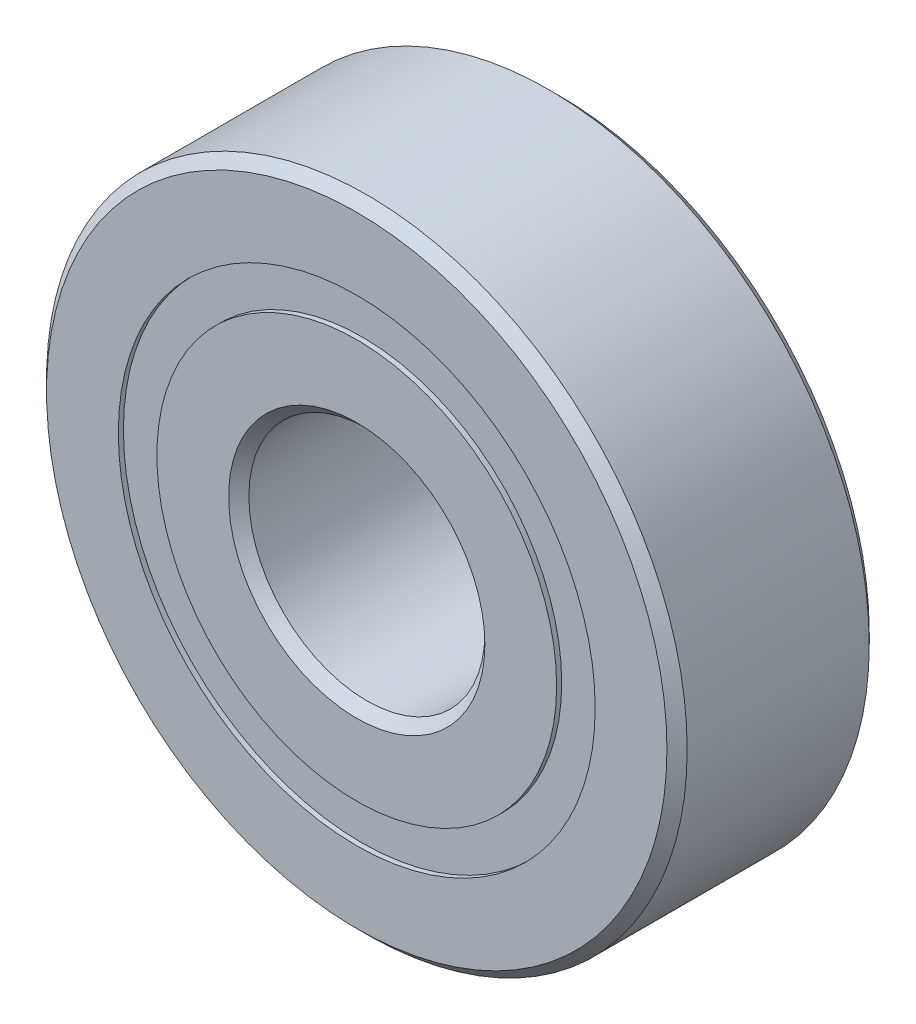
from build123d import *

# Parameters (mm, degrees)
CIRPATTERN1_COUNT = 12
SKETCH5_W         = 1.399376551
SKETCH5_H         = 1.142857142


with BuildPart() as part:
    # Sketch1 → Revolve1 (revolve)
    with BuildSketch(Plane(origin=(0, 0, 0), x_dir=(0, 0, -1), z_dir=(1, 0, 0))):
        with BuildLine():
            Line((2.7, 9.5), (-2.7, 9.5))
            Line((-2.7, 9.5), (-3, 9.2))
            Line((-3, 9.2), (-3, 7.071428571))
            Line((-3, 7.071428571), (-1.333333333, 7.071428571))
            ThreePointArc((-1.333333333, 7.071428571), (0, 7.950623449), (1.333333333, 7.071428571))
            Line((1.333333333, 7.071428571), (3, 7.071428571))
            Line((3, 7.071428571), (3, 9.2))
            Line((3, 9.2), (2.7, 9.5))
        make_face()
    revolve(axis=Axis((0, 0, 3), (0, 0, -1)))


with BuildPart() as body_2:
    # Sketch3 → Revolve3 (revolve)
    with BuildSketch(Plane(origin=(0, 0, 0), x_dir=(0, 0, -1), z_dir=(1, 0, 0))):
        with BuildLine():
            Line((-3, 5.928571429), (-1.333333333, 5.928571429))
            ThreePointArc((-1.333333333, 5.928571429), (0, 5.049376551), (1.333333333, 5.928571429))
            Line((1.333333333, 5.928571429), (3, 5.928571429))
            Line((3, 5.928571429), (3, 3.8))
            Line((3, 3.8), (2.7, 3.5))
            Line((2.7, 3.5), (-2.7, 3.5))
            Line((-2.7, 3.5), (-3, 3.8))
            Line((-3, 3.8), (-3, 5.928571429))
        make_face()
    revolve(axis=Axis((0, 0, 3), (0, 0, -1)))


with BuildPart() as body_3:
    # Sketch4 → Revolve4 (revolve)
    with BuildSketch(Plane(origin=(0, 0, 0), x_dir=(0, 0, -1), z_dir=(1, 0, 0))):
        with BuildLine():
            Line((-1.450623449, 6.5), (1.450623449, 6.5))
            ThreePointArc((1.450623449, 6.5), (0, 7.950623449), (-1.450623449, 6.5))
        make_face()
    revolve(axis=Axis((0, 6.5, 1.450623449), (0, 0, -1)))


with BuildPart() as cirpattern1_1:
    # CirPattern1: pattern copy
    add(body_3.part.rotate(Axis((0, 0, -3), (0, 0, 1)), 1 * 360 / CIRPATTERN1_COUNT))


with BuildPart() as cirpattern1_2:
    # CirPattern1: pattern copy
    add(body_3.part.rotate(Axis((0, 0, -3), (0, 0, 1)), 2 * 360 / CIRPATTERN1_COUNT))


with BuildPart() as cirpattern1_3:
    # CirPattern1: pattern copy
    add(body_3.part.rotate(Axis((0, 0, -3), (0, 0, 1)), 3 * 360 / CIRPATTERN1_COUNT))


with BuildPart() as cirpattern1_4:
    # CirPattern1: pattern copy
    add(body_3.part.rotate(Axis((0, 0, -3), (0, 0, 1)), 4 * 360 / CIRPATTERN1_COUNT))


with BuildPart() as cirpattern1_5:
    # CirPattern1: pattern copy
    add(body_3.part.rotate(Axis((0, 0, -3), (0, 0, 1)), 5 * 360 / CIRPATTERN1_COUNT))


with BuildPart() as cirpattern1_6:
    # CirPattern1: pattern copy
    add(body_3.part.rotate(Axis((0, 0, -3), (0, 0, 1)), 6 * 360 / CIRPATTERN1_COUNT))


with BuildPart() as cirpattern1_7:
    # CirPattern1: pattern copy
    add(body_3.part.rotate(Axis((0, 0, -3), (0, 0, 1)), 7 * 360 / CIRPATTERN1_COUNT))


with BuildPart() as cirpattern1_8:
    # CirPattern1: pattern copy
    add(body_3.part.rotate(Axis((0, 0, -3), (0, 0, 1)), 8 * 360 / CIRPATTERN1_COUNT))


with BuildPart() as cirpattern1_9:
    # CirPattern1: pattern copy
    add(body_3.part.rotate(Axis((0, 0, -3), (0, 0, 1)), 9 * 360 / CIRPATTERN1_COUNT))


with BuildPart() as cirpattern1_10:
    # CirPattern1: pattern copy
    add(body_3.part.rotate(Axis((0, 0, -3), (0, 0, 1)), 10 * 360 / CIRPATTERN1_COUNT))


with BuildPart() as cirpattern1_11:
    # CirPattern1: pattern copy
    add(body_3.part.rotate(Axis((0, 0, -3), (0, 0, 1)), 11 * 360 / CIRPATTERN1_COUNT))


with BuildPart() as body_15:
    # Sketch5 → Revolve5 (revolve)
    with BuildSketch(Plane(origin=(0, 0, 0), x_dir=(0, 0, -1), z_dir=(1, 0, 0))):
        with Locations((-2.150311724, 6.5)):
            Rectangle(SKETCH5_W, SKETCH5_H)
        with Locations((2.150311724, 6.5)):
            Rectangle(SKETCH5_W, SKETCH5_H)
    revolve(axis=Axis((0, 0, 3), (0, 0, -1)))


solid = Compound([part.part, body_2.part, body_3.part, cirpattern1_1.part, cirpattern1_2.part, cirpattern1_3.part, cirpattern1_4.part, cirpattern1_5.part, cirpattern1_6.part, cirpattern1_7.part, cirpattern1_8.part, cirpattern1_9.part, cirpattern1_10.part, cirpattern1_11.part, body_15.part])
